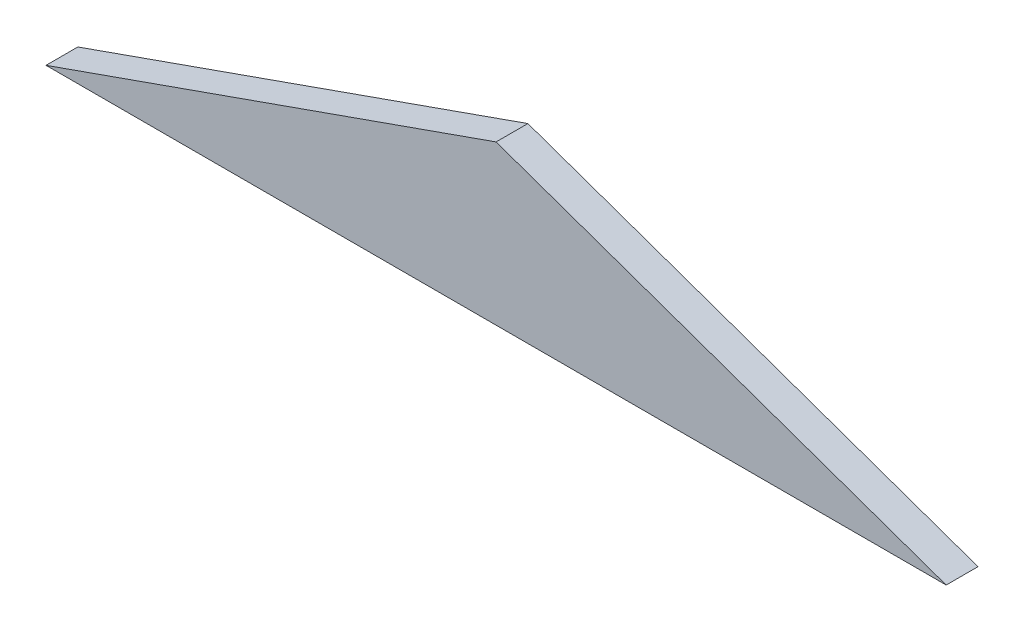
from build123d import *

# Parameters (mm, degrees)
BOSS_EXTRU_1_DEPTH = 3


with BuildPart() as part:
    # Esquisse1 → Boss.-Extru.1 (new body)
    with BuildSketch(Plane.XY):
        Polygon((42.438622075, 95.034594681), (-42.438622075, 95.034594681), (0, 110), align=None)
    extrude(amount=BOSS_EXTRU_1_DEPTH)


solid = part.part
